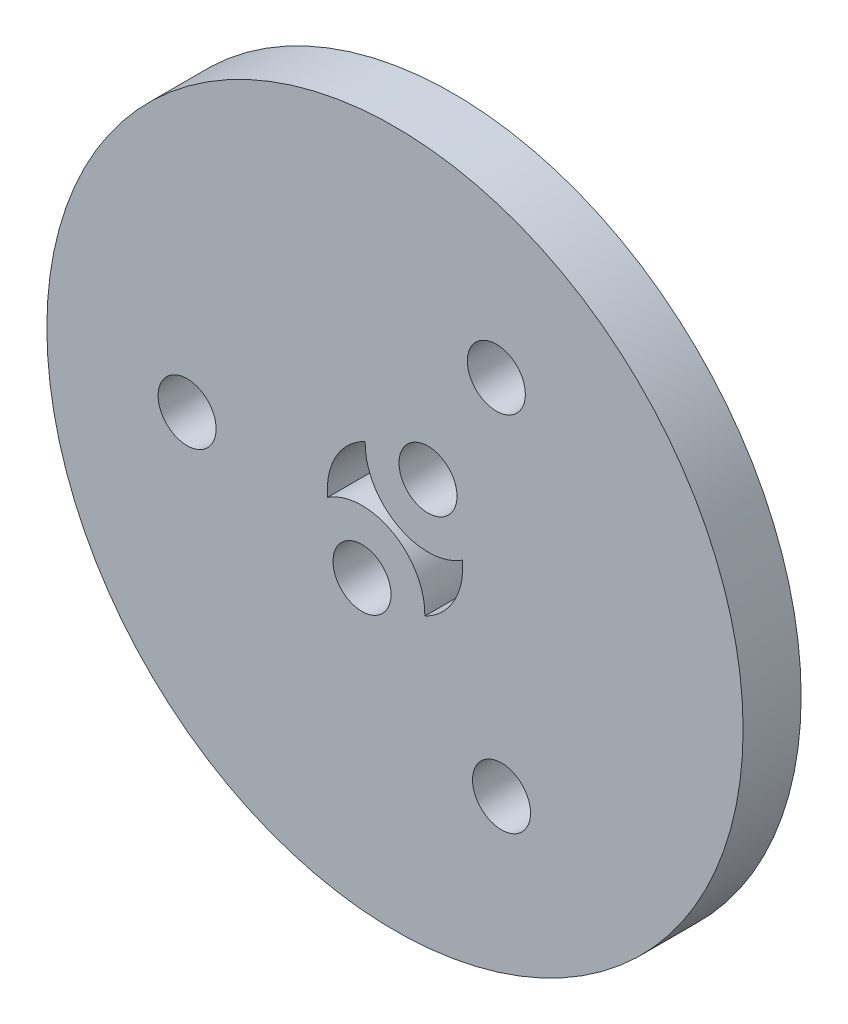
from build123d import *

# Parameters (mm, degrees)
ESQUISSE1_R        = 18
ESQUISSE1_R_2      = 1.5
BOSS_EXTRU_1_DEPTH = 3


with BuildPart() as part:
    # Esquisse1 → Boss.-Extru.1 (new body)
    with BuildSketch(Plane.XY):
        Circle(ESQUISSE1_R)
        with Locations((5.240453276, 9.386167986)):
            Circle(ESQUISSE1_R_2, mode=Mode.SUBTRACT)
        with Locations((-1.70619409, -3.05596167)):
            Circle(ESQUISSE1_R_2, mode=Mode.SUBTRACT)
        with Locations((1.70619409, 3.05596167)):
            Circle(ESQUISSE1_R_2, mode=Mode.SUBTRACT)
        with Locations((5.508433282, -9.231449657)):
            Circle(ESQUISSE1_R_2, mode=Mode.SUBTRACT)
        with Locations((-10.748886558, -0.154718329)):
            Circle(ESQUISSE1_R_2, mode=Mode.SUBTRACT)
        with BuildLine():
            ThreePointArc((1.54267531, -3.141679947), (-0.121871006, -0.218282976), (-3.483906341, -0.335256035))
            ThreePointArc((-3.483906341, -0.335256035), (-3.05596167, 1.70619409), (-1.54267531, 3.141679947))
            ThreePointArc((-1.54267531, 3.141679947), (0.121871006, 0.218282976), (3.483906341, 0.335256035))
            ThreePointArc((3.483906341, 0.335256035), (3.05596167, -1.70619409), (1.54267531, -3.141679947))
        make_face(mode=Mode.SUBTRACT)
    extrude(amount=BOSS_EXTRU_1_DEPTH)


solid = part.part
